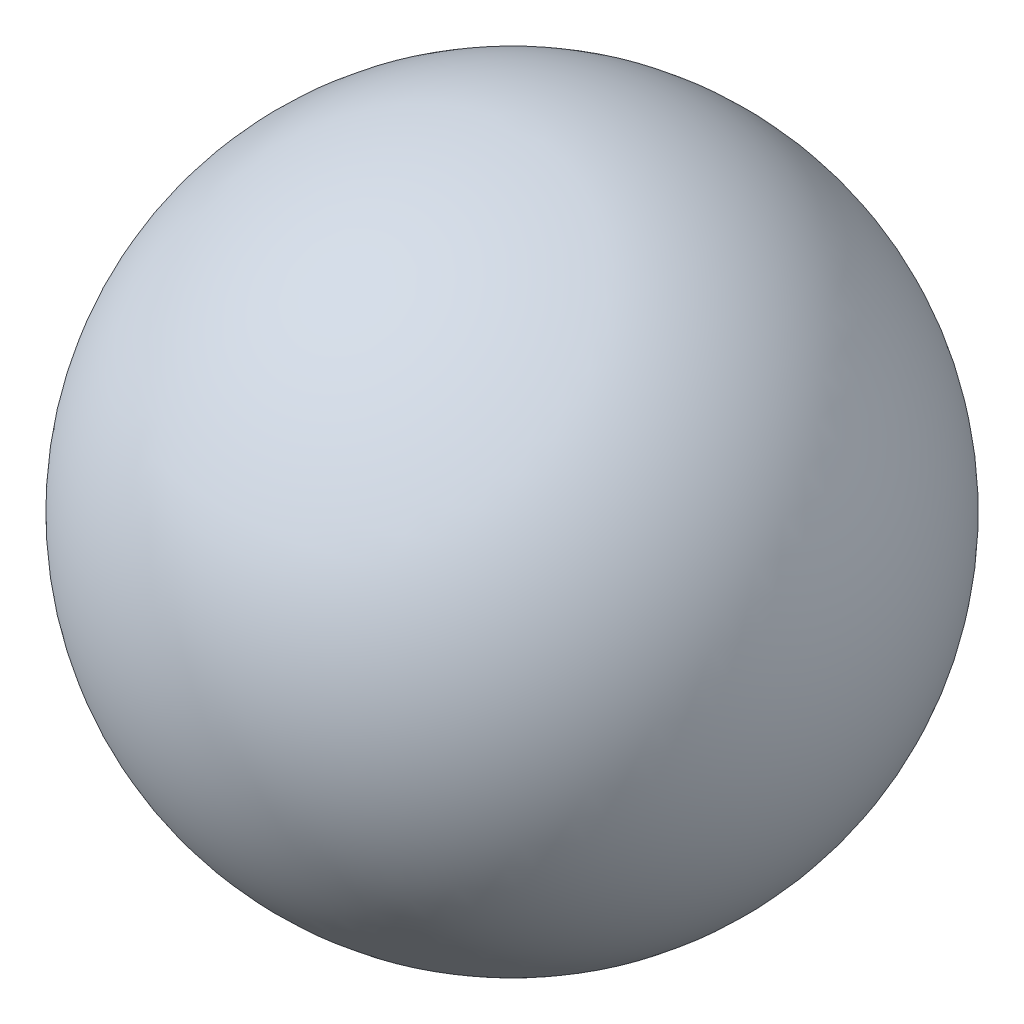
from build123d import *


with BuildPart() as part:
    # Sketch1 → Revolve1 (revolve)
    with BuildSketch(Plane.YZ):
        with BuildLine():
            Line((-20, 0), (20, 0))
            ThreePointArc((20, 0), (0, 20), (-20, 0))
        make_face()
    revolve(axis=Axis((0, 0, 0), (0, 1, 0)))


solid = part.part
